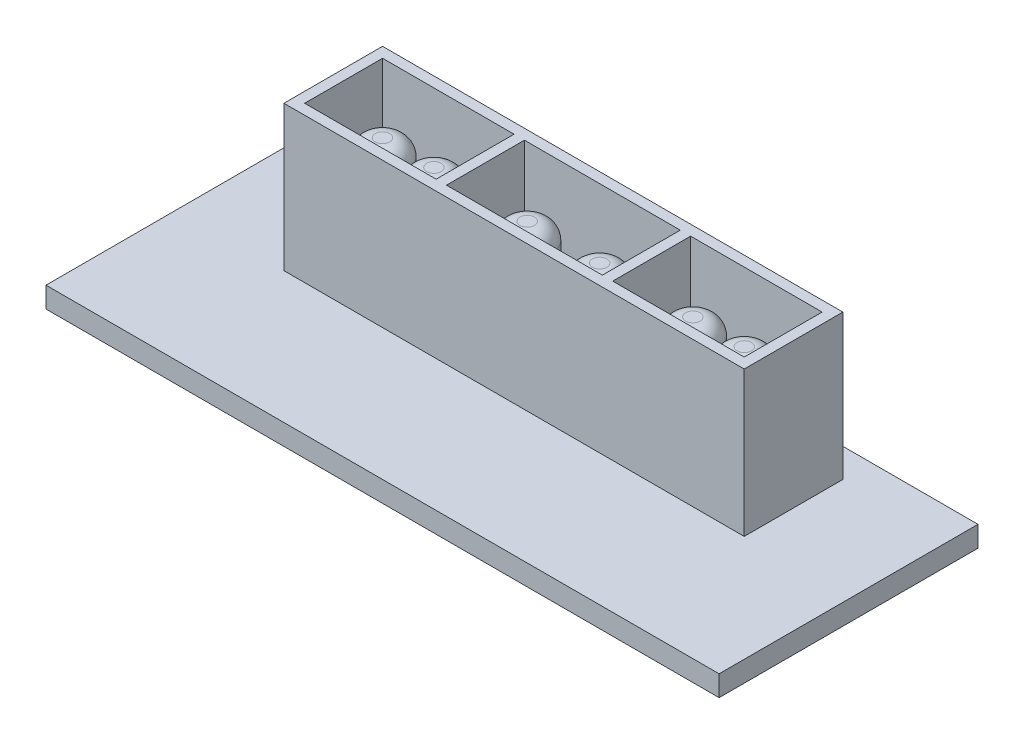
from build123d import *

# Parameters (mm, degrees)
SKETCH1_W           = 65
SKETCH1_H           = 25
BOSS_EXTRUDE1_DEPTH = 2
SKETCH2_W           = 44.45
SKETCH2_H           = 9.525
SKETCH2_W_2         = 12.7
SKETCH2_H_2         = 7.525
SKETCH2_W_3         = 15.049999936
BOSS_EXTRUDE2_DEPTH = 14
SKETCH3_R           = 2.299999953
BOSS_EXTRUDE4_DEPTH = 11.1125
FILLET2_R           = 1.6


with BuildPart() as part:
    # Sketch1 → Boss-Extrude1 (new body)
    with BuildSketch(Plane(origin=(0, 0, 0), x_dir=(1, 0, 0), z_dir=(0, 1, 0))):
        with Locations((-32.5, 12.5)):
            Rectangle(SKETCH1_W, SKETCH1_H)
    extrude(amount=BOSS_EXTRUDE1_DEPTH)

    # Sketch2 → Boss-Extrude2 (add)
    with BuildSketch(Plane(origin=(0, 2, 0), x_dir=(1, 0, 0), z_dir=(0, 1, 0))):
        with Locations((-32.5, 17.4625)):
            Rectangle(SKETCH2_W, SKETCH2_H)
        with Locations((-47.375, 17.4625)):
            Rectangle(SKETCH2_W_2, SKETCH2_H_2, mode=Mode.SUBTRACT)
        with Locations((-17.625, 17.4625)):
            Rectangle(SKETCH2_W_2, SKETCH2_H_2, mode=Mode.SUBTRACT)
        with Locations((-32.5, 17.4625)):
            Rectangle(SKETCH2_W_3, SKETCH2_H_2, mode=Mode.SUBTRACT)
    extrude(amount=BOSS_EXTRUDE2_DEPTH)

    # Sketch3 → Boss-Extrude4 (add)
    with BuildSketch(Plane(origin=(0, 2, 0), x_dir=(1, 0, 0), z_dir=(0, 1, 0))):
        with Locations((-36, 17.4625)):
            Circle(SKETCH3_R)
        with Locations((-49.97, 17.4625)):
            Circle(SKETCH3_R)
        with Locations((-19.998, 17.4625)):
            Circle(SKETCH3_R)
        with Locations((-29, 17.4625)):
            Circle(SKETCH3_R)
        with Locations((-15.03, 17.4625)):
            Circle(SKETCH3_R)
        with Locations((-45.002, 17.4625)):
            Circle(SKETCH3_R)
    extrude(amount=BOSS_EXTRUDE4_DEPTH)

    # Fillet2
    fillet2_edges = [part.edges().sort_by_distance(p)[0] for p in [
        (-38.299999953, 13.1125, -17.4625),
        (-52.269999953, 13.1125, -17.4625),
        (-22.297999953, 13.1125, -17.4625),
        (-31.299999953, 13.1125, -17.4625),
        (-17.329999953, 13.1125, -17.4625),
        (-47.301999953, 13.1125, -17.4625),
    ]]
    fillet(fillet2_edges, radius=FILLET2_R)


solid = part.part
